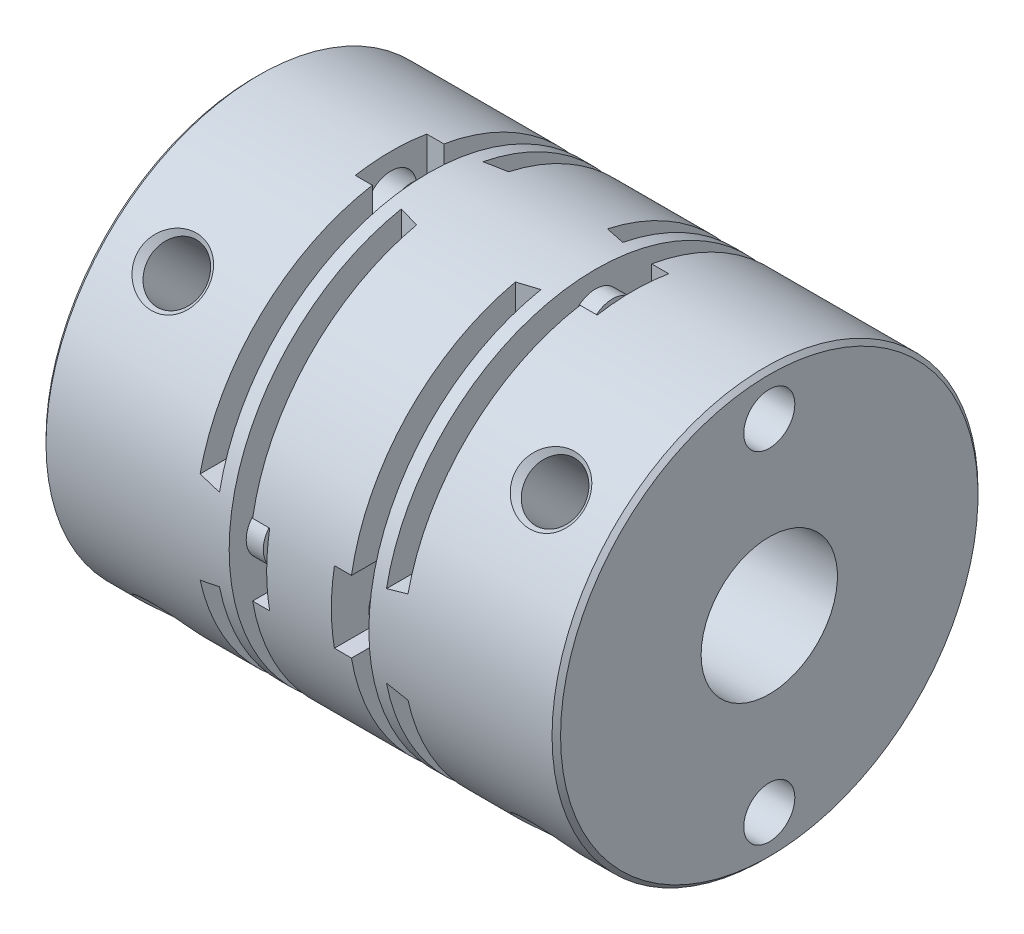
from build123d import *

# Parameters (mm, degrees)
CUT_EXTRUDE_1_DEPTH      = 12.5
CUT_EXTRUDE_1_DEPTH_BACK = 12.5
CUT_EXTRUDE_2_DEPTH      = 12.5
CUT_EXTRUDE_2_DEPTH_BACK = 12.5
CUT_EXTRUDE_3_DEPTH      = 12.5
CUT_EXTRUDE_3_DEPTH_BACK = 12.5
CUT_EXTRUDE_4_DEPTH      = 12.5
CUT_EXTRUDE_4_DEPTH_BACK = 12.5
CUT_EXTRUDE_5_DEPTH      = 1
CUT_EXTRUDE_6_DEPTH      = 1
CUT_EXTRUDE_START        = 1
CUT_EXTRUDE_7_DEPTH      = 1
CUT_EXTRUDE_8_DEPTH      = 1
CUT_EXTRUDE_9_DEPTH      = 1
CUT_EXTRUDE_10_DEPTH     = 1
CUT_EXTRUDE_11_DEPTH     = 1
CUT_EXTRUDE_12_DEPTH     = 1
SKETCH_18_R              = 1.5
EXTRUDE_1_DEPTH          = 1
SKETCH_19_R              = 1.5
EXTRUDE_2_DEPTH          = 1
SKETCH_20_R              = 1.5
EXTRUDE_3_DEPTH          = 1
SKETCH_21_R              = 1.5
EXTRUDE_4_DEPTH          = 1
EXTRUDE_START            = -1
SKETCH_22_R              = 1.5
EXTRUDE_5_DEPTH          = 1
SKETCH_23_R              = 1.5
EXTRUDE_6_DEPTH          = 1
EXTRUDE_START_2          = 1
SKETCH_24_R              = 1.5
EXTRUDE_7_DEPTH          = 1
SKETCH_25_R              = 1.5
EXTRUDE_8_DEPTH          = 1
HOLE_WIZARD_1_D          = 3
HOLE_WIZARD_1_DEPTH      = 9
HOLE_WIZARD_2_D          = 3
HOLE_WIZARD_2_DEPTH      = 9
HOLE_WIZARD_3_D          = 3
HOLE_WIZARD_3_DEPTH      = 9
HOLE_WIZARD_4_D          = 3
HOLE_WIZARD_4_DEPTH      = 9


with BuildPart() as part:
    # 草图1 → 旋转1 (revolve)
    with BuildSketch(Plane.XY):
        Polygon((0, 4), (9, 4), (9, 7.5), (10.2, 7.5), (10.2, 6), (11, 6), (11, 7.5), (12.2, 7.5), (12.2, 5.2), (18, 5.2), (18, 7.5), (19.2, 7.5), (19.2, 6), (20, 6), (20, 7.5), (21.2, 7.5), (21.2, 4), (30.2, 4), (30.2, 12.25), (29.95, 12.5), (0.25, 12.5), (0, 12.25), align=None)
    revolve(axis=Axis((30.2, 0, 0), (-1, 0, 0)))

    # 草图2 → 切除-旋转1 (revolve, cut)
    with BuildSketch(Plane(origin=(4, 0, 0), x_dir=(0, 0, -1), z_dir=(1, 0, 0))):
        Polygon((-8.838834765, 8.838834765), (-7.424621202, 10.253048327), (-7.424621202, 9.717061387), (1.146220092, 1.146220092), (0, 0), align=None)
    revolve(axis=Axis((4, 0, 0), (0, 0.7071067811865476, 0.7071067811865475)), mode=Mode.SUBTRACT)

    # 草图3 → 切除-旋转2 (revolve, cut)
    with BuildSketch(Plane(origin=(4, 0, 0), x_dir=(0, 0, -1), z_dir=(1, 0, 0))):
        Polygon((-8.838834765, -8.838834765), (-10.253048327, -7.424621202), (-9.717061387, -7.424621202), (-1.146220092, 1.146220092), (0, 0), align=None)
    revolve(axis=Axis((4, 0, 0), (0, -0.7071067811865475, 0.7071067811865476)), mode=Mode.SUBTRACT)

    # 草图4 → 切除-旋转3 (revolve, cut)
    with BuildSketch(Plane(origin=(26.2, 0, 0), x_dir=(0, 0, -1), z_dir=(1, 0, 0))):
        Polygon((-8.838834765, 8.838834765), (-7.424621202, 10.253048327), (-7.424621202, 9.717061387), (1.146220092, 1.146220092), (0, 0), align=None)
    revolve(axis=Axis((26.2, 0, 0), (0, 0.7071067811865476, 0.7071067811865475)), mode=Mode.SUBTRACT)

    # 草图5 → 切除-旋转4 (revolve, cut)
    with BuildSketch(Plane(origin=(26.2, 0, 0), x_dir=(0, 0, -1), z_dir=(1, 0, 0))):
        Polygon((-8.838834765, -8.838834765), (-10.253048327, -7.424621202), (-9.717061387, -7.424621202), (-1.146220092, 1.146220092), (0, 0), align=None)
    revolve(axis=Axis((26.2, 0, 0), (0, -0.7071067811865475, 0.7071067811865476)), mode=Mode.SUBTRACT)

    # 草图6 → 切除-拉伸1 (cut, two sides: drawn at the far end of the back side and taken through both)
    with BuildSketch(Plane.XY.offset(-CUT_EXTRUDE_1_DEPTH_BACK)):
        Polygon((9, 13), (9, 2.7), (10.2, 2.4), (10.2, 12.5), (20, 12.5), (20, 2.4), (21.2, 2.7), (21.2, 13), align=None)
    extrude(amount=CUT_EXTRUDE_1_DEPTH + CUT_EXTRUDE_1_DEPTH_BACK, mode=Mode.SUBTRACT)

    # 草图7 → 切除-拉伸2 (cut, two sides: drawn at the far end of the back side and taken through both)
    with BuildSketch(Plane.XY.offset(-CUT_EXTRUDE_2_DEPTH_BACK)):
        Polygon((9, -13), (21.2, -13), (21.2, -2.7), (20, -2.4), (20, -12.5), (10.2, -12.5), (10.2, -2.4), (9, -2.7), align=None)
    extrude(amount=CUT_EXTRUDE_2_DEPTH + CUT_EXTRUDE_2_DEPTH_BACK, mode=Mode.SUBTRACT)

    # 草图8 → 切除-拉伸3 (cut, two sides: drawn at the far end of the back side and taken through both)
    with BuildSketch(Plane(origin=(0, 0, 0), x_dir=(1, 0, 0), z_dir=(0, 1, 0)).offset(-CUT_EXTRUDE_3_DEPTH_BACK)):
        Polygon((11, 13), (11, 2.4), (12.2, 2.7), (12.2, 12.5), (18, 12.5), (18, 2.7), (19.2, 2.4), (19.2, 13), align=None)
    extrude(amount=CUT_EXTRUDE_3_DEPTH + CUT_EXTRUDE_3_DEPTH_BACK, mode=Mode.SUBTRACT)

    # 草图9 → 切除-拉伸4 (cut, two sides: drawn at the far end of the back side and taken through both)
    with BuildSketch(Plane(origin=(0, 0, 0), x_dir=(1, 0, 0), z_dir=(0, 1, 0)).offset(-CUT_EXTRUDE_4_DEPTH_BACK)):
        Polygon((11, -13), (19.2, -13), (19.2, -2.4), (18, -2.7), (18, -12.5), (12.2, -12.5), (12.2, -2.7), (11, -2.4), align=None)
    extrude(amount=CUT_EXTRUDE_4_DEPTH + CUT_EXTRUDE_4_DEPTH_BACK, mode=Mode.SUBTRACT)

    # 草图10 → 切除-拉伸5 (cut)
    with BuildSketch(Plane(origin=(18, 0, 0), x_dir=(0, 0, -1), z_dir=(1, 0, 0))):
        with BuildLine():
            Line((-12.5, -2.1), (-10, -2.1))
            ThreePointArc((-10, -2.1), (-7.9, 0), (-10, 2.1))
            Line((-10, 2.1), (-12.5, 2.1))
            Line((-12.5, 2.1), (-12.5, -2.1))
        make_face()
    extrude(amount=-CUT_EXTRUDE_5_DEPTH, mode=Mode.SUBTRACT)

    # 草图11 → 切除-拉伸6 (cut)
    with BuildSketch(Plane(origin=(18, 0, 0), x_dir=(0, 0, -1), z_dir=(1, 0, 0))):
        with BuildLine():
            Line((10, -2.1), (12.5, -2.1))
            Line((12.5, -2.1), (12.5, 2.1))
            Line((12.5, 2.1), (10, 2.1))
            ThreePointArc((10, 2.1), (7.9, 0), (10, -2.1))
        make_face()
    extrude(amount=-CUT_EXTRUDE_6_DEPTH, mode=Mode.SUBTRACT)

    # 草图12 → 切除-拉伸7 (cut)
    with BuildSketch(Plane(origin=(12.2, 0, 0), x_dir=(0, 0, -1), z_dir=(1, 0, 0)).offset(CUT_EXTRUDE_START)):
        with BuildLine():
            Line((-12.5, -2.1), (-10, -2.1))
            ThreePointArc((-10, -2.1), (-7.9, 0), (-10, 2.1))
            Line((-10, 2.1), (-12.5, 2.1))
            Line((-12.5, 2.1), (-12.5, -2.1))
        make_face()
    extrude(amount=-CUT_EXTRUDE_7_DEPTH, mode=Mode.SUBTRACT)

    # 草图13 → 切除-拉伸8 (cut)
    with BuildSketch(Plane(origin=(12.2, 0, 0), x_dir=(0, 0, -1), z_dir=(1, 0, 0)).offset(CUT_EXTRUDE_START)):
        with BuildLine():
            Line((10, -2.1), (12.5, -2.1))
            Line((12.5, -2.1), (12.5, 2.1))
            Line((12.5, 2.1), (10, 2.1))
            ThreePointArc((10, 2.1), (7.9, 0), (10, -2.1))
        make_face()
    extrude(amount=-CUT_EXTRUDE_8_DEPTH, mode=Mode.SUBTRACT)

    # 草图14 → 切除-拉伸9 (cut)
    with BuildSketch(Plane(origin=(9, 0, 0), x_dir=(0, 0, -1), z_dir=(1, 0, 0))):
        with BuildLine():
            Line((2.1, 10), (2.1, 12.5))
            Line((2.1, 12.5), (-2.1, 12.5))
            Line((-2.1, 12.5), (-2.1, 10))
            ThreePointArc((-2.1, 10), (0, 7.9), (2.1, 10))
        make_face()
    extrude(amount=-CUT_EXTRUDE_9_DEPTH, mode=Mode.SUBTRACT)

    # 草图15 → 切除-拉伸10 (cut)
    with BuildSketch(Plane(origin=(9, 0, 0), x_dir=(0, 0, -1), z_dir=(1, 0, 0))):
        with BuildLine():
            Line((-2.1, -10), (-2.1, -12.5))
            Line((-2.1, -12.5), (2.1, -12.5))
            Line((2.1, -12.5), (2.1, -10))
            ThreePointArc((2.1, -10), (0, -7.9), (-2.1, -10))
        make_face()
    extrude(amount=-CUT_EXTRUDE_10_DEPTH, mode=Mode.SUBTRACT)

    # 草图16 → 切除-拉伸11 (cut)
    with BuildSketch(Plane(origin=(21.2, 0, 0), x_dir=(0, 0, -1), z_dir=(1, 0, 0)).offset(CUT_EXTRUDE_START)):
        with BuildLine():
            Line((2.1, 10), (2.1, 12.5))
            Line((2.1, 12.5), (-2.1, 12.5))
            Line((-2.1, 12.5), (-2.1, 10))
            ThreePointArc((-2.1, 10), (0, 7.9), (2.1, 10))
        make_face()
    extrude(amount=-CUT_EXTRUDE_11_DEPTH, mode=Mode.SUBTRACT)

    # 草图17 → 切除-拉伸12 (cut)
    with BuildSketch(Plane(origin=(21.2, 0, 0), x_dir=(0, 0, -1), z_dir=(1, 0, 0)).offset(CUT_EXTRUDE_START)):
        with BuildLine():
            Line((-2.1, -10), (-2.1, -12.5))
            Line((-2.1, -12.5), (2.1, -12.5))
            Line((2.1, -12.5), (2.1, -10))
            ThreePointArc((2.1, -10), (0, -7.9), (-2.1, -10))
        make_face()
    extrude(amount=-CUT_EXTRUDE_12_DEPTH, mode=Mode.SUBTRACT)

    # 草图18 → 凸台-拉伸1 (add)
    with BuildSketch(Plane(origin=(11, 0, 0), x_dir=(0, 0, -1), z_dir=(1, 0, 0))):
        with Locations((-10, 0)):
            Circle(SKETCH_18_R)
    extrude(amount=EXTRUDE_1_DEPTH)

    # 草图19 → 凸台-拉伸2 (add)
    with BuildSketch(Plane(origin=(11, 0, 0), x_dir=(0, 0, -1), z_dir=(1, 0, 0))):
        with Locations((10, 0)):
            Circle(SKETCH_19_R)
    extrude(amount=EXTRUDE_2_DEPTH)

    # 草图20 → 凸台-拉伸3 (add)
    with BuildSketch(Plane(origin=(10.2, 0, 0), x_dir=(0, 0, -1), z_dir=(1, 0, 0))):
        with Locations((0, 10)):
            Circle(SKETCH_20_R)
    extrude(amount=-EXTRUDE_3_DEPTH)

    # 草图21 → 凸台-拉伸4 (add)
    with BuildSketch(Plane(origin=(10.2, 0, 0), x_dir=(0, 0, -1), z_dir=(1, 0, 0))):
        with Locations((0, -10)):
            Circle(SKETCH_21_R)
    extrude(amount=-EXTRUDE_4_DEPTH)

    # 草图22 → 凸台-拉伸5 (add)
    with BuildSketch(Plane(origin=(19.2, 0, 0), x_dir=(0, 0, -1), z_dir=(1, 0, 0)).offset(EXTRUDE_START)):
        with Locations((-10, 0)):
            Circle(SKETCH_22_R)
    extrude(amount=EXTRUDE_5_DEPTH)

    # 草图23 → 凸台-拉伸6 (add)
    with BuildSketch(Plane(origin=(19.2, 0, 0), x_dir=(0, 0, -1), z_dir=(1, 0, 0)).offset(EXTRUDE_START)):
        with Locations((10, 0)):
            Circle(SKETCH_23_R)
    extrude(amount=EXTRUDE_6_DEPTH)

    # 草图24 → 凸台-拉伸7 (add)
    with BuildSketch(Plane(origin=(20, 0, 0), x_dir=(0, 0, -1), z_dir=(1, 0, 0)).offset(EXTRUDE_START_2)):
        with Locations((0, 10)):
            Circle(SKETCH_24_R)
    extrude(amount=-EXTRUDE_7_DEPTH)

    # 草图25 → 凸台-拉伸8 (add)
    with BuildSketch(Plane(origin=(20, 0, 0), x_dir=(0, 0, -1), z_dir=(1, 0, 0)).offset(EXTRUDE_START_2)):
        with Locations((0, -10)):
            Circle(SKETCH_25_R)
    extrude(amount=-EXTRUDE_8_DEPTH)

    # 孔1
    with Locations(Plane.ZY):
        with Locations((0, 10)):
            Hole(HOLE_WIZARD_1_D / 2, depth=HOLE_WIZARD_1_DEPTH)

    # 孔2
    with Locations(Plane.ZY):
        with Locations((0, -10)):
            Hole(HOLE_WIZARD_2_D / 2, depth=HOLE_WIZARD_2_DEPTH)

    # 孔3
    with Locations(Plane(origin=(30.2, 0, 0), x_dir=(0, 0, -1), z_dir=(1, 0, 0))):
        with Locations((0, 10)):
            Hole(HOLE_WIZARD_3_D / 2, depth=HOLE_WIZARD_3_DEPTH)

    # 孔4
    with Locations(Plane(origin=(30.2, 0, 0), x_dir=(0, 0, -1), z_dir=(1, 0, 0))):
        with Locations((0, -10)):
            Hole(HOLE_WIZARD_4_D / 2, depth=HOLE_WIZARD_4_DEPTH)


solid = part.part
